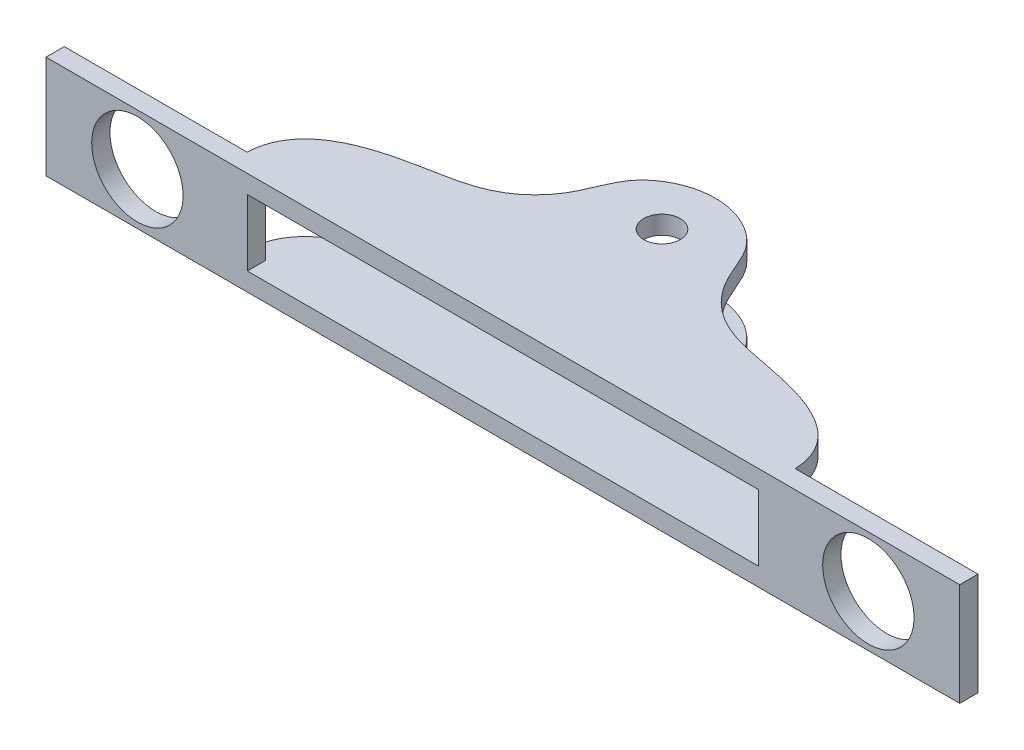
from build123d import *

# Parameters (mm, degrees)
SKETCH2_R           = 1.27
BOSS_EXTRUDE1_DEPTH = 3.571875
SKETCH2_3_R         = 1.27
CUT_EXTRUDE1_DEPTH  = 2.301875
SKETCH3_R           = 3.175
SKETCH3_W           = 35.514246082
SKETCH3_H           = 4.60375
CUT_EXTRUDE2_DEPTH  = 4.60375


with BuildPart() as part:
    # Sketch2 → Boss-Extrude1 (new, symmetric)
    with BuildSketch(Plane(origin=(0, 0, 0), x_dir=(1, 0, 0), z_dir=(0, 1, 0))):
        with BuildLine():
            Line((-19.05, 0), (-31.75, 0))
            Line((-31.75, 0), (-31.75, -1.27))
            Line((-31.75, -1.27), (31.75, -1.27))
            Line((31.75, -1.27), (31.75, 0))
            Line((31.75, 0), (19.05, 0))
            add(Edge.make_bspline(
                [(19.05, 0), (18.924950207, 3.11249949), (13.871376527, 5.182684851), (8.100418146, 5.640691885), (5.150487062, 8.710773905), (4.233787006, 12.334614196), (1.464765989, 13.525214321), (0, 13.497480559)],
                knots=[0, 0, 0, 0, 0.332448712, 0.564615599, 0.691987457, 0.817131748, 1, 1, 1, 1], degree=3))
            add(Edge.make_bspline(
                [(-19.05, 0), (-18.924950207, 3.11249949), (-13.871376527, 5.182684851), (-8.100418146, 5.640691885), (-5.150487062, 8.710773905), (-4.233787006, 12.334614196), (-1.464765989, 13.525214321), (0, 13.497480559)],
                knots=[0, 0, 0, 0, 0.332448712, 0.564615599, 0.691987457, 0.817131748, 1, 1, 1, 1], degree=3))
        make_face()
        with Locations((0, 9.787802422)):
            Circle(SKETCH2_R, mode=Mode.SUBTRACT)
    extrude(amount=BOSS_EXTRUDE1_DEPTH, both=True)

    # Sketch2_3 → Cut-Extrude1 (cut, symmetric)
    with BuildSketch(Plane(origin=(0, 0, 0), x_dir=(1, 0, 0), z_dir=(0, 1, 0))):
        with BuildLine():
            add(Edge.make_bspline(
                [(-19.05, 0), (-18.924950207, 3.11249949), (-13.871376527, 5.182684851), (-8.100418146, 5.640691885), (-5.150487062, 8.710773905), (-4.233787006, 12.334614196), (-1.464765989, 13.525214321), (0, 13.497480559)],
                knots=[0, 0, 0, 0, 0.332448712, 0.564615599, 0.691987457, 0.817131748, 1, 1, 1, 1], degree=3))
            Line((-19.05, 0), (19.05, 0))
            add(Edge.make_bspline(
                [(19.05, 0), (18.924950207, 3.11249949), (13.871376527, 5.182684851), (8.100418146, 5.640691885), (5.150487062, 8.710773905), (4.233787006, 12.334614196), (1.464765989, 13.525214321), (0, 13.497480559)],
                knots=[0, 0, 0, 0, 0.332448712, 0.564615599, 0.691987457, 0.817131748, 1, 1, 1, 1], degree=3))
        make_face()
        with Locations((0, 9.787802422)):
            Circle(SKETCH2_3_R, mode=Mode.SUBTRACT)
    extrude(amount=CUT_EXTRUDE1_DEPTH, both=True, mode=Mode.SUBTRACT)

    # Sketch3 → Cut-Extrude2 (cut)
    with BuildSketch(Plane(origin=(0, 0, 0), x_dir=(-1, 0, 0), z_dir=(0, 0, -1))):
        with Locations((-25.4, 0)):
            Circle(SKETCH3_R)
        with Locations((25.4, 0)):
            Circle(SKETCH3_R)
        Rectangle(SKETCH3_W, SKETCH3_H)
    extrude(amount=-CUT_EXTRUDE2_DEPTH, mode=Mode.SUBTRACT)


solid = part.part
